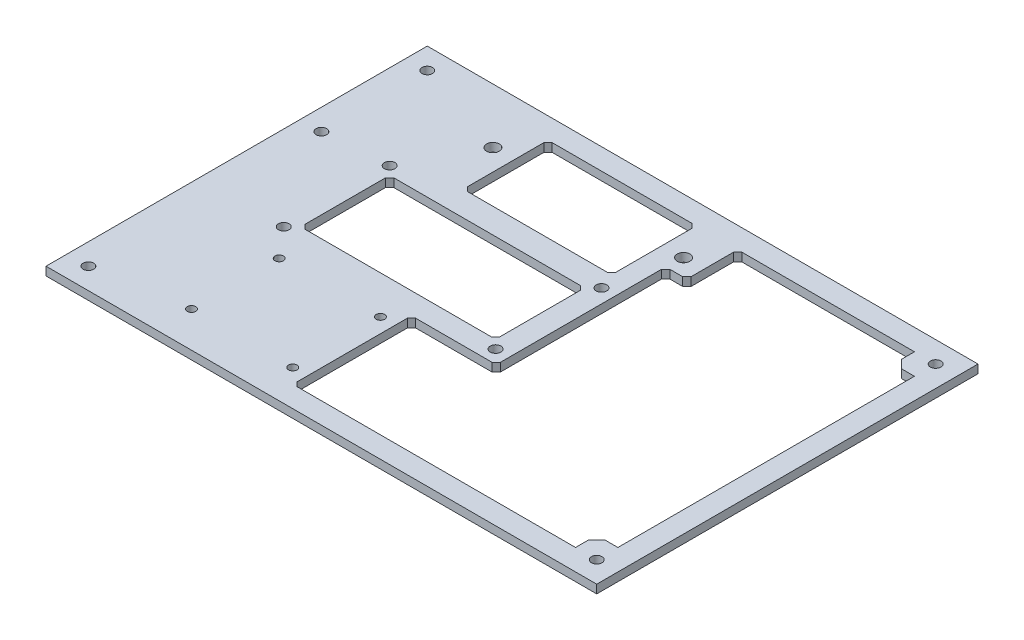
from build123d import *

# Parameters (mm, degrees)
ESQUISSE1_W             = 130
ESQUISSE1_H             = 90
BOSS_EXTRU_1_DEPTH      = 2
ESQUISSE2_R             = 1.5
ESQUISSE2_R_2           = 1.25
ESQUISSE2_R_3           = 1
ENL_V_MAT_EXTRU_1_DEPTH = 2
ENL_V_MAT_EXTRU_2_DEPTH = 10
ENL_V_MAT_EXTRU_3_DEPTH = 10
ENL_V_MAT_EXTRU_4_DEPTH = 10


with BuildPart() as part:
    # Esquisse1 → Boss.-Extru.1 (new body)
    with BuildSketch(Plane(origin=(0, 0, 0), x_dir=(1, 0, 0), z_dir=(0, 1, 0))):
        with Locations((-15.798192771, -19.450301205)):
            Rectangle(ESQUISSE1_W, ESQUISSE1_H)
    extrude(amount=BOSS_EXTRU_1_DEPTH)

    # Esquisse2 → Enlèv. mat.-Extru.1 (cut)
    with BuildSketch(Plane(origin=(0, 2, 0), x_dir=(1, 0, 0), z_dir=(0, 1, 0))):
        with Locations(Location((-52.298192771, 12.549698795, 0), (0, 0, 270))):  # turned: the seam where the file's is
            Circle(ESQUISSE2_R)
        with Locations(Location((-7.298192771, 12.549698795, 0), (0, 0, 270))):  # turned: the seam where the file's is
            Circle(ESQUISSE2_R)
        with Locations(Location((-60.798192771, -3.330301205, 0), (0, 0, 270))):  # turned: the seam where the file's is
            Circle(ESQUISSE2_R_2)
        with Locations(Location((-10.798192771, -3.330301205, 0), (0, 0, 270))):  # turned: the seam where the file's is
            Circle(ESQUISSE2_R_2)
        with Locations(Location((-10.798192771, -28.330301205, 0), (0, 0, 270))):  # turned: the seam where the file's is
            Circle(ESQUISSE2_R_2)
        with Locations(Location((-60.798192771, -28.330301205, 0), (0, 0, 270))):  # turned: the seam where the file's is
            Circle(ESQUISSE2_R_2)
        with Locations(Location((-54.868192771, -35.330301205, 0), (0, 0, 270))):  # turned: the seam where the file's is
            Circle(ESQUISSE2_R_3)
        with Locations(Location((-30.968192771, -35.330301205, 0), (0, 0, 270))):  # turned: the seam where the file's is
            Circle(ESQUISSE2_R_3)
        with Locations(Location((-30.968192771, -56.030301205, 0), (0, 0, 270))):  # turned: the seam where the file's is
            Circle(ESQUISSE2_R_3)
        with Locations(Location((-54.868192771, -56.030301205, 0), (0, 0, 270))):  # turned: the seam where the file's is
            Circle(ESQUISSE2_R_3)
        with Locations(Location((-75.798192771, -4.450301205, 0), (0, 0, 270))):  # turned: the seam where the file's is
            Circle(ESQUISSE2_R_2)
        with Locations(Location((-75.798192771, -59.450301205, 0), (0, 0, 270))):  # turned: the seam where the file's is
            Circle(ESQUISSE2_R_2)
        with Locations(Location((44.201807229, 20.549698795, 0), (0, 0, 270))):  # turned: the seam where the file's is
            Circle(ESQUISSE2_R_2)
        with Locations(Location((44.201807229, -59.450301205, 0), (0, 0, 270))):  # turned: the seam where the file's is
            Circle(ESQUISSE2_R_2)
        with Locations(Location((-75.798192771, 20.549698795, 0), (0, 0, 270))):  # turned: the seam where the file's is
            Circle(ESQUISSE2_R_2)
    extrude(amount=-ENL_V_MAT_EXTRU_1_DEPTH, mode=Mode.SUBTRACT)

    # Esquisse3 → Enlèv. mat.-Extru.2 (cut)
    with BuildSketch(Plane(origin=(0, 2, 0), x_dir=(1, 0, 0), z_dir=(0, 1, 0))):
        Polygon((39.201807229, 20.549698795), (-1.521135019, 20.549698795), (-2.521135019, 19.549698795), (-2.521135019, 9.549698795), (-3.521135019, 8.549698795), (-6.521135019, 8.549698795), (-7.521135019, 7.549698795), (-7.521135019, -30.450301205), (-8.521135019, -31.450301205), (-26.521135019, -31.450301205), (-27.521135019, -32.450301205), (-27.521135019, -58.450301205), (-26.521135019, -59.450301205), (39.201807229, -59.450301205), (39.201807229, -56.450301205), (41.201807229, -54.450301205), (44.201807229, -54.450301205), (44.201807229, 15.549698795), (41.201807229, 15.549698795), (39.201807229, 17.549698795), align=None)
    extrude(amount=-ENL_V_MAT_EXTRU_2_DEPTH, mode=Mode.SUBTRACT)

    # Esquisse4 → Enlèv. mat.-Extru.3 (cut)
    with BuildSketch(Plane(origin=(0, 2, 0), x_dir=(1, 0, 0), z_dir=(0, 1, 0))):
        Polygon((-58.798192771, -6.330301205), (-57.798192771, -5.330301205), (-13.798192771, -5.330301205), (-12.798192771, -6.330301205), (-12.798192771, -25.330301205), (-13.798192771, -26.330301205), (-57.798192771, -26.330301205), (-58.798192771, -25.330301205), align=None)
    extrude(amount=-ENL_V_MAT_EXTRU_3_DEPTH, mode=Mode.SUBTRACT)

    # Esquisse5 → Enlèv. mat.-Extru.4 (cut)
    with BuildSketch(Plane(origin=(0, 2, 0), x_dir=(1, 0, 0), z_dir=(0, 1, 0))):
        Polygon((-46.298192771, 20.549698795), (-13.298192771, 20.549698795), (-12.298192771, 19.549698795), (-12.298192771, 1.549698795), (-13.298192771, 0.549698795), (-46.298192771, 0.549698795), (-47.298192771, 1.549698795), (-47.298192771, 19.549698795), align=None)
    extrude(amount=-ENL_V_MAT_EXTRU_4_DEPTH, mode=Mode.SUBTRACT)


solid = part.part
